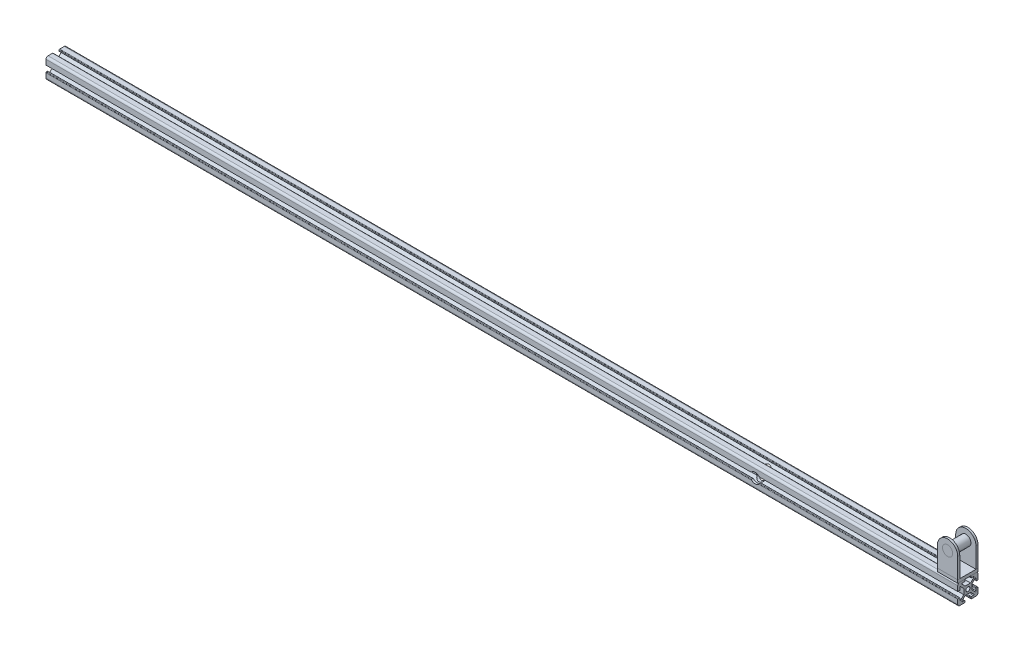
from build123d import *

# Parameters (mm, degrees)
SKETCH2_R                       = 2
ALUMINIUM_PROFILE_20_20_1_DEPTH = 1000
SKETCH3_R                       = 5
CUT_EXTRUDE1_DEPTH              = 50
SKETCH10_W                      = 53.187273646
SKETCH10_H                      = 37.053500666
CUT_EXTRUDE5_DEPTH              = 100
SKETCH14_W                      = 20
SKETCH14_H                      = 20
BOSS_EXTRUDE3_DEPTH             = 3
SKETCH16_R                      = 5
BOSS_EXTRUDE4_DEPTH             = 2
SKETCH17_R                      = 5.040181095
BOSS_EXTRUDE5_DEPTH             = 2
SKETCH18_R                      = 5
BOSS_EXTRUDE6_DEPTH             = 20


with BuildPart() as part:
    # Sketch2 → Aluminium profile 20×20(1) (new body)
    with BuildSketch(Plane(origin=(0, 0, 0), x_dir=(0, -1, 0), z_dir=(-1, 0, 0))):
        with BuildLine():
            Line((-2.666639653, -4), (2.666639653, -4))
            Line((2.666639653, -4), (5.776647091, -7.148635412))
            ThreePointArc((5.776647091, -7.148635412), (5.882265465, -7.692766317), (5.420918365, -8))
            Line((5.420918365, -8), (3.498570355, -8))
            ThreePointArc((3.498570355, -8), (3.145016964, -8.146446609), (2.998570355, -8.5))
            Line((2.998570355, -8.5), (2.998570355, -9.5))
            ThreePointArc((2.998570355, -9.5), (3.145016964, -9.853553391), (3.498570355, -10))
            Line((3.498570355, -10), (7.998570355, -10))
            ThreePointArc((7.998570355, -10), (9.412783917, -9.414213562), (9.998570355, -8))
            Line((9.998570355, -8), (9.998570355, -3.5))
            ThreePointArc((9.998570355, -3.5), (9.852123746, -3.146446609), (9.498570355, -3))
            Line((9.498570355, -3), (8.498570355, -3))
            ThreePointArc((8.498570355, -3), (8.145016964, -3.146446609), (7.998570355, -3.5))
            Line((7.998570355, -3.5), (7.998570355, -5.412091861))
            ThreePointArc((7.998570355, -5.412091861), (7.691000546, -5.873579263), (7.146687869, -5.767308297))
            Line((7.146687869, -5.767308297), (4, -2.650154242))
            Line((4, -2.650154242), (4, 2.650154242))
            Line((4, 2.650154242), (7.146687869, 5.767308297))
            ThreePointArc((7.146687869, 5.767308297), (7.691000546, 5.873579263), (7.998570355, 5.412091861))
            Line((7.998570355, 5.412091861), (7.998570355, 3.5))
            ThreePointArc((7.998570355, 3.5), (8.145016964, 3.146446609), (8.498570355, 3))
            Line((8.498570355, 3), (9.498570355, 3))
            ThreePointArc((9.498570355, 3), (9.852123746, 3.146446609), (9.998570355, 3.5))
            Line((9.998570355, 3.5), (9.998570355, 8))
            ThreePointArc((9.998570355, 8), (9.412783917, 9.414213562), (7.998570355, 10))
            Line((7.998570355, 10), (3.498570355, 10))
            ThreePointArc((3.498570355, 10), (3.145016964, 9.853553391), (2.998570355, 9.5))
            Line((2.998570355, 9.5), (2.998570355, 8.5))
            ThreePointArc((2.998570355, 8.5), (3.145016964, 8.146446609), (3.498570355, 8))
            Line((3.498570355, 8), (5.420918365, 8))
            ThreePointArc((5.420918365, 8), (5.882265465, 7.692766317), (5.776647091, 7.148635412))
            Line((5.776647091, 7.148635412), (2.666639653, 4))
            Line((2.666639653, 4), (-2.666639653, 4))
            Line((-2.666639653, 4), (-5.776647091, 7.148635412))
            ThreePointArc((-5.776647091, 7.148635412), (-5.882265465, 7.692766317), (-5.420918365, 8))
            Line((-5.420918365, 8), (-2.998570355, 8))
            Line((-2.998570355, 8), (-2.998570355, 10))
            Line((-2.998570355, 10), (-7.998570355, 10))
            ThreePointArc((-7.998570355, 10), (-9.412783917, 9.414213562), (-9.998570355, 8))
            Line((-9.998570355, 8), (-9.998570355, 3.5))
            ThreePointArc((-9.998570355, 3.5), (-9.852123746, 3.146446609), (-9.498570355, 3))
            Line((-9.498570355, 3), (-8.498570355, 3))
            ThreePointArc((-8.498570355, 3), (-8.145016964, 3.146446609), (-7.998570355, 3.5))
            Line((-7.998570355, 3.5), (-7.998570355, 5.412091861))
            ThreePointArc((-7.998570355, 5.412091861), (-7.691000546, 5.873579263), (-7.146687869, 5.767308297))
            Line((-7.146687869, 5.767308297), (-4, 2.650154242))
            Line((-4, 2.650154242), (-4, -2.650154242))
            Line((-4, -2.650154242), (-7.146687869, -5.767308297))
            ThreePointArc((-7.146687869, -5.767308297), (-7.691000546, -5.873579263), (-7.998570355, -5.412091861))
            Line((-7.998570355, -5.412091861), (-7.998570355, -3.5))
            ThreePointArc((-7.998570355, -3.5), (-8.145016964, -3.146446609), (-8.498570355, -3))
            Line((-8.498570355, -3), (-9.498570355, -3))
            ThreePointArc((-9.498570355, -3), (-9.852123746, -3.146446609), (-9.998570355, -3.5))
            Line((-9.998570355, -3.5), (-9.998570355, -8))
            ThreePointArc((-9.998570355, -8), (-9.412783917, -9.414213562), (-7.998570355, -10))
            Line((-7.998570355, -10), (-3.498570355, -10))
            ThreePointArc((-3.498570355, -10), (-3.145016964, -9.853553391), (-2.998570355, -9.5))
            Line((-2.998570355, -9.5), (-2.998570355, -8.5))
            ThreePointArc((-2.998570355, -8.5), (-3.145016964, -8.146446609), (-3.498570355, -8))
            Line((-3.498570355, -8), (-5.420918365, -8))
            ThreePointArc((-5.420918365, -8), (-5.882265465, -7.692766317), (-5.776647091, -7.148635412))
            Line((-5.776647091, -7.148635412), (-2.666639653, -4))
        make_face()
        Circle(SKETCH2_R, mode=Mode.SUBTRACT)
    extrude(amount=ALUMINIUM_PROFILE_20_20_1_DEPTH)

    # Sketch3 → Cut-Extrude1 (cut)
    with BuildSketch(Plane.XY.offset(10)):
        with Locations(Location((-300, 0, 0), (0, 0, 327.769413306))):
            Circle(SKETCH3_R)
    extrude(amount=-CUT_EXTRUDE1_DEPTH, mode=Mode.SUBTRACT)

    # Sketch10 → Cut-Extrude5 (cut)
    with BuildSketch(Plane(origin=(0, 0, 0), x_dir=(0, 0, -1), z_dir=(1, 0, 0))):
        Rectangle(SKETCH10_W, SKETCH10_H)
    extrude(amount=-CUT_EXTRUDE5_DEPTH, mode=Mode.SUBTRACT)


with BuildPart() as body_2:
    # Sketch14 → Boss-Extrude3 (new body)
    with BuildSketch(Plane(origin=(0, 9.998570355, 0), x_dir=(1, 0, 0), z_dir=(0, 1, 0))):
        with Locations((-110, 0)):
            Rectangle(SKETCH14_W, SKETCH14_H)
    extrude(amount=BOSS_EXTRUDE3_DEPTH)


with BuildPart() as body_3:
    # Sketch16 → Boss-Extrude4 (new body)
    with BuildSketch(Plane.XY.offset(10)):
        with BuildLine():
            Line((-120, 12.998570355), (-100, 12.998570355))
            Line((-100, 12.998570355), (-100, 32.998570355))
            ThreePointArc((-100, 32.998570355), (-110, 42.998570355), (-120, 32.998570355))
            Line((-120, 32.998570355), (-120, 12.998570355))
        make_face()
        with Locations((-110, 32.998570355)):
            Circle(SKETCH16_R, mode=Mode.SUBTRACT)
    extrude(amount=-BOSS_EXTRUDE4_DEPTH)


with BuildPart() as body_4:
    # Sketch17 → Boss-Extrude5 (new body)
    with BuildSketch(Plane(origin=(0, 0, -10), x_dir=(-1, 0, 0), z_dir=(0, 0, -1))):
        with BuildLine():
            Line((100, 12.998570355), (120, 12.998570355))
            Line((120, 12.998570355), (120, 32.95838926))
            ThreePointArc((120, 32.95838926), (110, 42.95838926), (100, 32.95838926))
            Line((100, 32.95838926), (100, 12.998570355))
        make_face()
        with Locations((110, 32.95838926)):
            Circle(SKETCH17_R, mode=Mode.SUBTRACT)
    extrude(amount=-BOSS_EXTRUDE5_DEPTH)


with BuildPart() as body_5:
    # Sketch18 → Boss-Extrude6 (new body)
    with BuildSketch(Plane(origin=(0, 0, -10), x_dir=(-1, 0, 0), z_dir=(0, 0, -1))):
        with Locations((110, 32.998570355)):
            Circle(SKETCH18_R)
    extrude(amount=-BOSS_EXTRUDE6_DEPTH)


solid = Compound([part.part, body_2.part, body_3.part, body_4.part, body_5.part])
